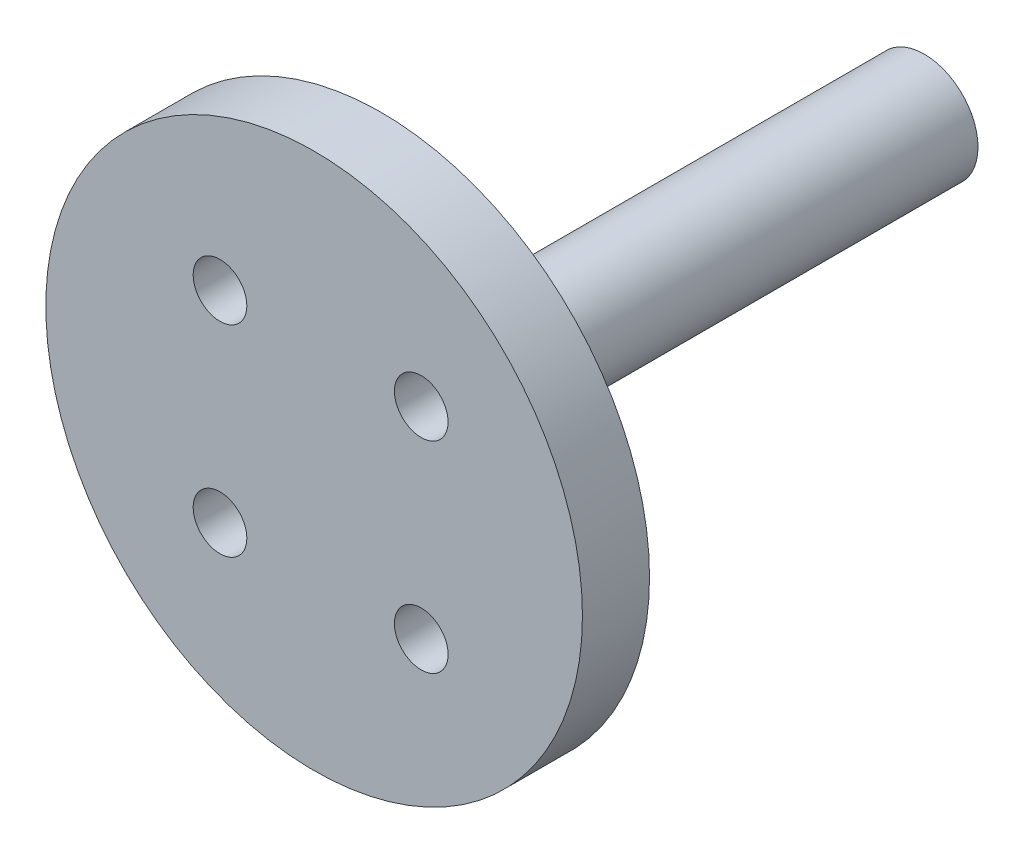
from build123d import *

# Parameters (mm, degrees)
SKETCH1_R           = 20
BOSS_EXTRUDE1_DEPTH = 5
SKETCH2_R           = 2
CUT_EXTRUDE1_DEPTH  = 30
SKETCH3_R           = 4
BOSS_EXTRUDE3_DEPTH = 40
SKETCH4_R           = 2.5
CUT_EXTRUDE2_DEPTH  = 16


with BuildPart() as part:
    # Sketch1 → Boss-Extrude1 (new body)
    with BuildSketch(Plane.XY):
        with Locations((-0.483808042, 0)):
            Circle(SKETCH1_R)
    extrude(amount=BOSS_EXTRUDE1_DEPTH)

    # Sketch2 → Cut-Extrude1 (cut)
    with BuildSketch(Plane(origin=(0, 0, 0), x_dir=(-1, 0, 0), z_dir=(0, 0, -1))):
        with Locations((7.5, 7.5)):
            Circle(SKETCH2_R)
        with Locations((7.5, -7.5)):
            Circle(SKETCH2_R)
        with Locations((-7.5, -7.5)):
            Circle(SKETCH2_R)
        with Locations((-7.5, 7.5)):
            Circle(SKETCH2_R)
    extrude(amount=-CUT_EXTRUDE1_DEPTH, mode=Mode.SUBTRACT)

    # Sketch3 → Boss-Extrude3 (add)
    with BuildSketch(Plane(origin=(0, 0, 0), x_dir=(-1, 0, 0), z_dir=(0, 0, -1))):
        Circle(SKETCH3_R)
    extrude(amount=BOSS_EXTRUDE3_DEPTH)

    # Sketch4 → Cut-Extrude2 (cut)
    with BuildSketch(Plane(origin=(0, 0, -40), x_dir=(-1, 0, 0), z_dir=(0, 0, -1))):
        Circle(SKETCH4_R)
    extrude(amount=-CUT_EXTRUDE2_DEPTH, mode=Mode.SUBTRACT)


solid = part.part
